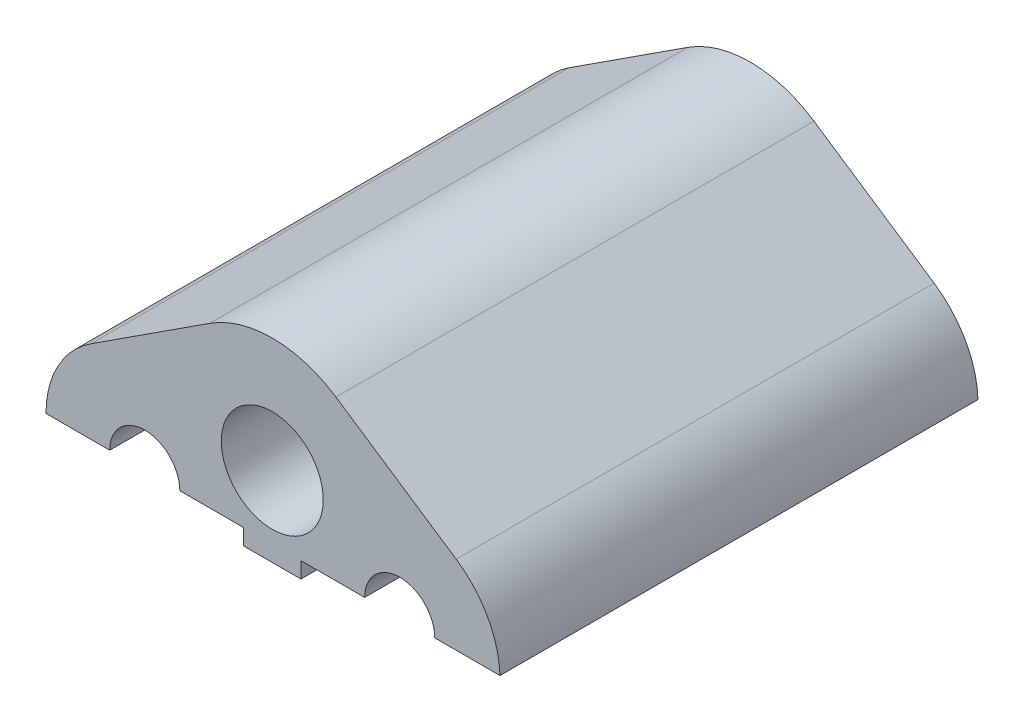
from build123d import *

# Parameters (mm, degrees)
SKETCH1_R           = 1.1
SKETCH1_R_2         = 1.6
BOSS_EXTRUDE1_DEPTH = 15
CUT_EXTRUDE1_DEPTH  = 15
SKETCH4_W           = 1.8
SKETCH4_H           = 0.5
BOSS_EXTRUDE2_DEPTH = 15


with BuildPart() as part:
    # Sketch1 → Boss-Extrude1 (new body)
    with BuildSketch(Plane.XY):
        with BuildLine():
            Line((-1.61243197, 5.01974999), (-5.34022711, 2.600340269))
            ThreePointArc((-5.34022711, 2.600340269), (-6.625018483, -0.880041239), (-3.652556975, -3.1))
            Line((-3.652556975, -3.1), (4.395993446, -3.201847309))
            ThreePointArc((4.395993446, -3.201847309), (7.362670385, -1.001195929), (6.117333323, 2.476328214))
            Line((6.117333323, 2.476328214), (2.346418367, 4.994010285))
            ThreePointArc((2.346418367, 4.994010285), (0.370849058, 5.59992391), (-1.61243197, 5.01974999))
        make_face()
        with Locations((4.347443025, 0)):
            Circle(SKETCH1_R, mode=Mode.SUBTRACT)
        with Locations((0.347443025, 2)):
            Circle(SKETCH1_R_2, mode=Mode.SUBTRACT)
        with Locations((-3.652556975, 0)):
            Circle(SKETCH1_R, mode=Mode.SUBTRACT)
    extrude(amount=BOSS_EXTRUDE1_DEPTH)

    # Sketch3 → Cut-Extrude1 (cut)
    with BuildSketch(Plane.XY.offset(15)):
        with BuildLine():
            Line((-3.652556975, -3.1), (-3.652556975, -1.1))
            ThreePointArc((-3.652556975, -1.1), (-4.430374434, -0.777817459), (-4.752556975, 0))
            Line((-4.752556975, 0), (-6.752556975, 0))
            ThreePointArc((-6.752556975, 0), (-5.844587997, -2.192031022), (-3.652556975, -3.1))
        make_face()
        with BuildLine():
            Line((3.247443025, 0), (-2.552556975, 0))
            ThreePointArc((-2.552556975, 0), (-2.874739516, -0.777817459), (-3.652556975, -1.1))
            Line((-3.652556975, -1.1), (-3.652556975, -3.1))
            Line((-3.652556975, -3.1), (4.395993446, -3.201847309))
            ThreePointArc((4.395993446, -3.201847309), (6.623741934, -2.257569154), (7.49431995, 0))
            Line((7.49431995, 0), (5.447443025, 0))
            ThreePointArc((5.447443025, 0), (4.347443025, -1.1), (3.247443025, 0))
        make_face()
        with BuildLine():
            Line((-3.652556975, -4.774585684), (-3.652556975, -3.1))
            ThreePointArc((-3.652556975, -3.1), (-5.844587997, -2.192031022), (-6.752556975, 0))
            Line((-6.752556975, 0), (-12.259555469, 0))
            Line((-12.259555469, 0), (-12.259555469, -4.774585684))
            Line((-12.259555469, -4.774585684), (-3.652556975, -4.774585684))
        make_face()
        with BuildLine():
            Line((4.395993446, -3.201847309), (-3.652556975, -3.1))
            Line((-3.652556975, -3.1), (-3.652556975, -4.774585684))
            Line((-3.652556975, -4.774585684), (12.655202498, -4.774585684))
            Line((12.655202498, -4.774585684), (12.655202498, 0))
            Line((12.655202498, 0), (7.49431995, 0))
            ThreePointArc((7.49431995, 0), (6.623741934, -2.257569154), (4.395993446, -3.201847309))
        make_face()
    extrude(amount=-CUT_EXTRUDE1_DEPTH, mode=Mode.SUBTRACT)

    # Sketch4 → Boss-Extrude2 (add)
    with BuildSketch(Plane.XY.offset(15)):
        with Locations((0.347443025, -0.25)):
            Rectangle(SKETCH4_W, SKETCH4_H)
    extrude(amount=-BOSS_EXTRUDE2_DEPTH)


solid = part.part
